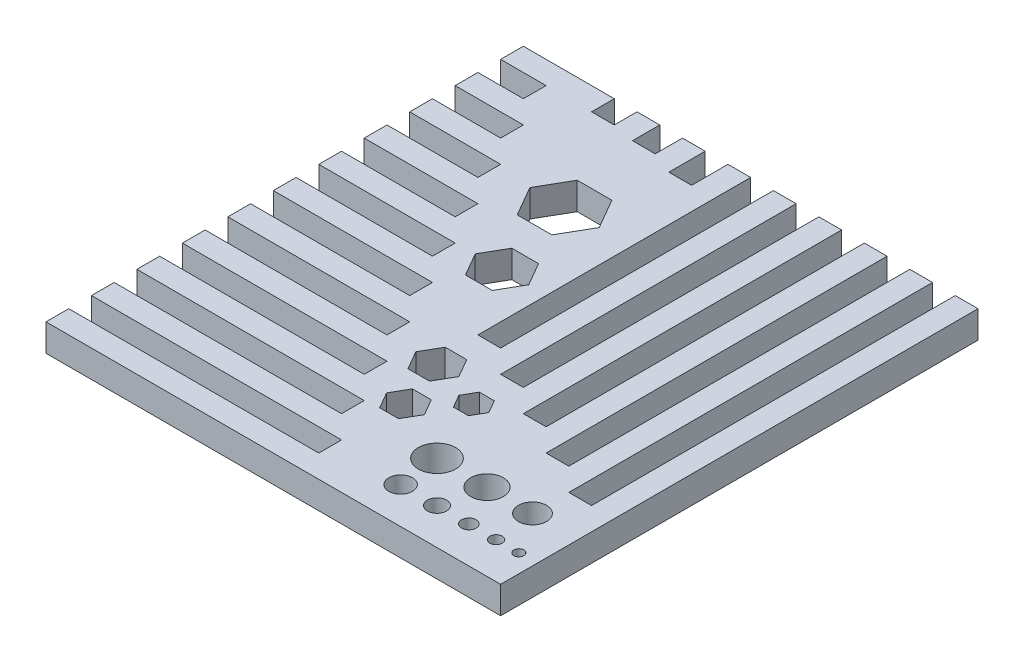
from build123d import *

# Parameters (mm, degrees)
SKETCH1_W           = 100
SKETCH1_H           = 105
BOSS_EXTRUDE1_DEPTH = 6
SKETCH3_W           = 10
SKETCH3_H           = 5
SKETCH3_W_2         = 15
SKETCH3_W_3         = 20
SKETCH3_W_4         = 25
SKETCH3_W_5         = 30
SKETCH3_W_6         = 35
SKETCH3_W_7         = 40
SKETCH3_W_8         = 45
SKETCH3_W_9         = 50
SKETCH3_W_10        = 55
CUT_EXTRUDE1_DEPTH  = 6
SKETCH4_W           = 5
SKETCH4_H           = 80
SKETCH4_H_2         = 75
SKETCH4_H_3         = 70
SKETCH4_H_4         = 65
SKETCH4_H_5         = 60
CUT_EXTRUDE2_DEPTH  = 6
SKETCH5_R           = 1.35
SKETCH5_R_2         = 1.6
SKETCH5_R_3         = 2.1
SKETCH5_R_4         = 2.6
SKETCH5_R_5         = 1.1
SKETCH5_R_6         = 3.1
SKETCH5_R_7         = 3.6
SKETCH5_R_8         = 4.1
CUT_EXTRUDE3_DEPTH  = 7
SKETCH7_W           = 5
SKETCH7_H           = 5
SKETCH7_H_2         = 6
SKETCH7_H_3         = 8
CUT_EXTRUDE4_DEPTH  = 7
CUT_EXTRUDE5_DEPTH  = 7


with BuildPart() as part:
    # Sketch1 → Boss-Extrude1 (new body)
    with BuildSketch(Plane(origin=(0, 0, 0), x_dir=(1, 0, 0), z_dir=(0, 1, 0))):
        with Locations((50, 52.5)):
            Rectangle(SKETCH1_W, SKETCH1_H)
    extrude(amount=BOSS_EXTRUDE1_DEPTH)

    # Sketch3 → Cut-Extrude1 (cut)
    with BuildSketch(Plane(origin=(0, 6, 0), x_dir=(1, 0, 0), z_dir=(0, 1, 0))):
        with Locations((5, 97.5)):
            Rectangle(SKETCH3_W, SKETCH3_H)
        with Locations((7.5, 87.5)):
            Rectangle(SKETCH3_W_2, SKETCH3_H)
        with Locations((10, 77.5)):
            Rectangle(SKETCH3_W_3, SKETCH3_H)
        with Locations((12.5, 67.5)):
            Rectangle(SKETCH3_W_4, SKETCH3_H)
        with Locations((15, 57.5)):
            Rectangle(SKETCH3_W_5, SKETCH3_H)
        with Locations((17.5, 47.5)):
            Rectangle(SKETCH3_W_6, SKETCH3_H)
        with Locations((20, 37.5)):
            Rectangle(SKETCH3_W_7, SKETCH3_H)
        with Locations((22.5, 27.5)):
            Rectangle(SKETCH3_W_8, SKETCH3_H)
        with Locations((25, 17.5)):
            Rectangle(SKETCH3_W_9, SKETCH3_H)
        with Locations((27.5, 7.5)):
            Rectangle(SKETCH3_W_10, SKETCH3_H)
    extrude(amount=-CUT_EXTRUDE1_DEPTH, mode=Mode.SUBTRACT)

    # Sketch4 → Cut-Extrude2 (cut)
    with BuildSketch(Plane(origin=(0, 6, 0), x_dir=(1, 0, 0), z_dir=(0, 1, 0))):
        with Locations((92.5, 65)):
            Rectangle(SKETCH4_W, SKETCH4_H)
        with Locations((82.5, 67.5)):
            Rectangle(SKETCH4_W, SKETCH4_H_2)
        with Locations((72.5, 70)):
            Rectangle(SKETCH4_W, SKETCH4_H_3)
        with Locations((62.5, 72.5)):
            Rectangle(SKETCH4_W, SKETCH4_H_4)
        with Locations((52.5, 75)):
            Rectangle(SKETCH4_W, SKETCH4_H_5)
    extrude(amount=-CUT_EXTRUDE2_DEPTH, mode=Mode.SUBTRACT)

    # Sketch5 → Cut-Extrude3 (cut, through all)
    with BuildSketch(Plane(origin=(0, 6, 0), x_dir=(1, 0, 0), z_dir=(0, 1, 0))):
        with Locations((91, 8)):
            Circle(SKETCH5_R)
        with Locations((85, 8)):
            Circle(SKETCH5_R_2)
        with Locations((78, 8)):
            Circle(SKETCH5_R_3)
        with Locations((70, 8)):
            Circle(SKETCH5_R_4)
        with Locations((96, 8)):
            Circle(SKETCH5_R_5)
        with Locations((90, 17)):
            Circle(SKETCH5_R_6)
        with Locations((80, 17)):
            Circle(SKETCH5_R_7)
        with Locations((69, 17)):
            Circle(SKETCH5_R_8)
    extrude(amount=-CUT_EXTRUDE3_DEPTH, mode=Mode.SUBTRACT)

    # Sketch7 → Cut-Extrude4 (cut, through all)
    with BuildSketch(Plane(origin=(0, 6, 0), x_dir=(1, 0, 0), z_dir=(0, 1, 0))):
        with Locations((22.5, 102.5)):
            Rectangle(SKETCH7_W, SKETCH7_H)
        with Locations((32.5, 102)):
            Rectangle(SKETCH7_W, SKETCH7_H_2)
        with Locations((42.5, 101)):
            Rectangle(SKETCH7_W, SKETCH7_H_3)
    extrude(amount=-CUT_EXTRUDE4_DEPTH, mode=Mode.SUBTRACT)

    # Sketch8 → Cut-Extrude5 (cut, through all)
    with BuildSketch(Plane(origin=(0, 6, 0), x_dir=(1, 0, 0), z_dir=(0, 1, 0))):
        Polygon((65.986104675, 31.416856683), (64.340656408, 34.266856683), (61.049759874, 34.266856683), (59.404311607, 31.416856683), (61.049759874, 28.566856683), (64.340656408, 28.566856683), align=None)
        Polygon((59.309574734, 23.921668245), (57.231113764, 27.521668245), (53.074191826, 27.521668245), (50.995730857, 23.921668245), (53.074191826, 20.321668245), (57.231113764, 20.321668245), align=None)
        Polygon((55.845473118, 34.972078883), (53.478337015, 39.072078883), (48.744064807, 39.072078883), (46.376928704, 34.972078883), (48.744064807, 30.872078883), (53.478337015, 30.872078883), align=None)
        Polygon((46.037567534, 60.151166507), (43.093081161, 65.251166507), (37.204108416, 65.251166507), (34.259622043, 60.151166507), (37.204108416, 55.051166507), (43.093081161, 55.051166507), align=None)
        Polygon((42.884078391, 78.793578101), (39.073566615, 85.393578101), (31.452543062, 85.393578101), (27.642031285, 78.793578101), (31.452543062, 72.193578101), (39.073566615, 72.193578101), align=None)
    extrude(amount=-CUT_EXTRUDE5_DEPTH, mode=Mode.SUBTRACT)


solid = part.part
